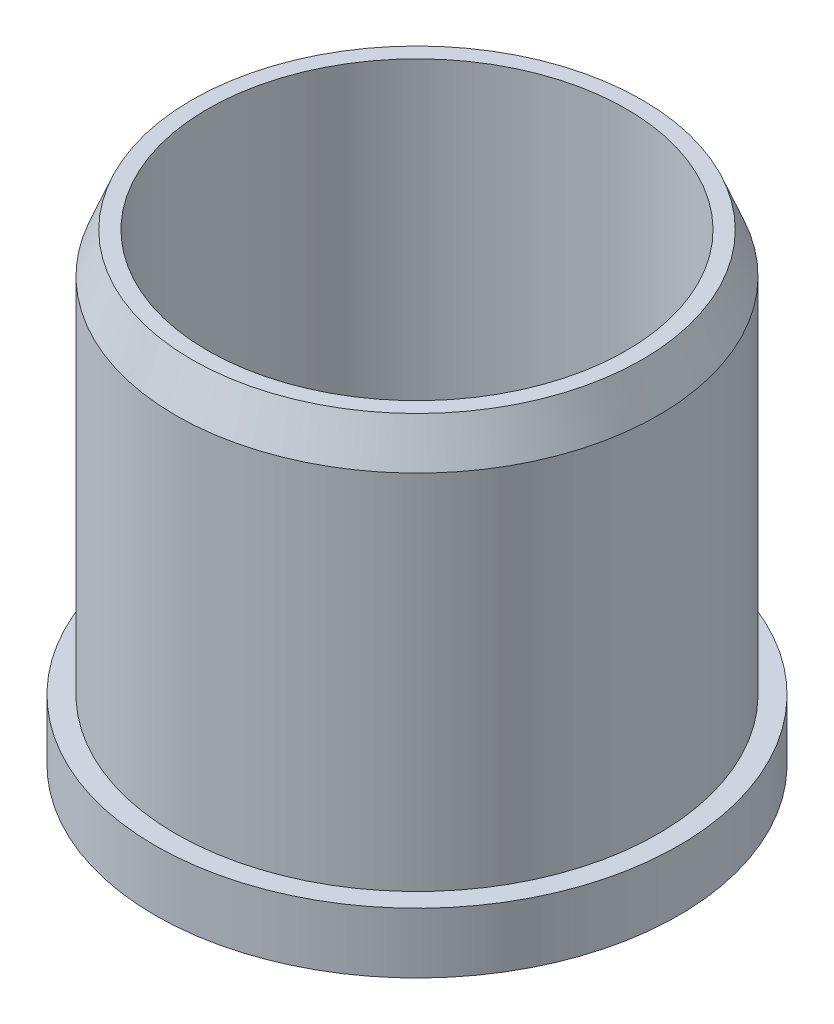
from build123d import *

# Parameters (mm, degrees)
SKETCH1_R           = 41.275
SKETCH1_R_2         = 7.62
BOSS_EXTRUDE1_DEPTH = 9.525
SKETCH2_R           = 38.0365
SKETCH2_R_2         = 33.02
BOSS_EXTRUDE2_DEPTH = 63.5
SKETCH3_R           = 12.7
BOSS_EXTRUDE3_DEPTH = 15.875
CHAMFER1_SIZE       = 6.35
CHAMFER1_SIZE2      = 2.54
SKETCH4_R           = 12.7
BOSS_EXTRUDE4_DEPTH = 6.35
FILLET1_R           = 2.54


with BuildPart() as part:
    # Sketch1 → Boss-Extrude1 (new body)
    with BuildSketch(Plane(origin=(0, 0, 0), x_dir=(1, 0, 0), z_dir=(0, 1, 0))):
        Circle(SKETCH1_R)
        with Locations((-13.436770867, -18.494128491)):
            Circle(SKETCH1_R_2, mode=Mode.SUBTRACT)
        with Locations((13.436770867, -18.494128491)):
            Circle(SKETCH1_R_2, mode=Mode.SUBTRACT)
        with BuildLine():
            Line((9.6, -2.5), (6.64529909, -2.5))
            ThreePointArc((6.64529909, -2.5), (-7.1, 0), (6.64529909, 2.5))
            Line((6.64529909, 2.5), (9.6, 2.5))
            Line((9.6, 2.5), (9.6, -2.5))
        make_face(mode=Mode.SUBTRACT)
        with Locations((-21.741151963, 7.064128491)):
            Circle(SKETCH1_R_2, mode=Mode.SUBTRACT)
        with BuildLine():
            ThreePointArc((0, 15.24), (-7.62, 22.86), (0, 30.48))
            ThreePointArc((0, 30.48), (7.62, 22.86), (0, 15.24))
        make_face(mode=Mode.SUBTRACT)
        with Locations((21.741151963, 7.064128491)):
            Circle(SKETCH1_R_2, mode=Mode.SUBTRACT)
    extrude(amount=BOSS_EXTRUDE1_DEPTH)

    # Sketch2 → Boss-Extrude2 (add)
    with BuildSketch(Plane(origin=(0, 9.525, 0), x_dir=(1, 0, 0), z_dir=(0, 1, 0))):
        Circle(SKETCH2_R)
        Circle(SKETCH2_R_2, mode=Mode.SUBTRACT)
    extrude(amount=BOSS_EXTRUDE2_DEPTH)

    # Sketch3 → Boss-Extrude3 (add)
    with BuildSketch(Plane(origin=(0, 9.525, 0), x_dir=(1, 0, 0), z_dir=(0, 1, 0))):
        Circle(SKETCH3_R)
        with BuildLine():
            Line((9.6, -2.5), (6.64529909, -2.5))
            ThreePointArc((6.64529909, -2.5), (-7.1, 0), (6.64529909, 2.5))
            Line((6.64529909, 2.5), (9.6, 2.5))
            Line((9.6, 2.5), (9.6, -2.5))
        make_face(mode=Mode.SUBTRACT)
    extrude(amount=BOSS_EXTRUDE3_DEPTH)

    # Chamfer1
    chamfer1_edges = [part.edges().sort_by_distance(p)[0] for p in [
        (-38.0365, 73.025, 0),
    ]]
    chamfer1_side = [part.faces().sort_by_distance(p)[0] for p in [
        (-38.0365, 41.275, 0),
    ]]
    chamfer(chamfer1_edges, length=CHAMFER1_SIZE, length2=CHAMFER1_SIZE2, reference=chamfer1_side[0])

    # Sketch4 → Boss-Extrude4 (add)
    with BuildSketch(Plane(origin=(0, 25.4, 0), x_dir=(1, 0, 0), z_dir=(0, 1, 0))):
        Circle(SKETCH4_R)
    extrude(amount=BOSS_EXTRUDE4_DEPTH)

    # Fillet1
    fillet1_edges = [part.edges().sort_by_distance(p)[0] for p in [
        (-12.7, 31.75, 0),
    ]]
    fillet(fillet1_edges, radius=FILLET1_R)


solid = part.part
